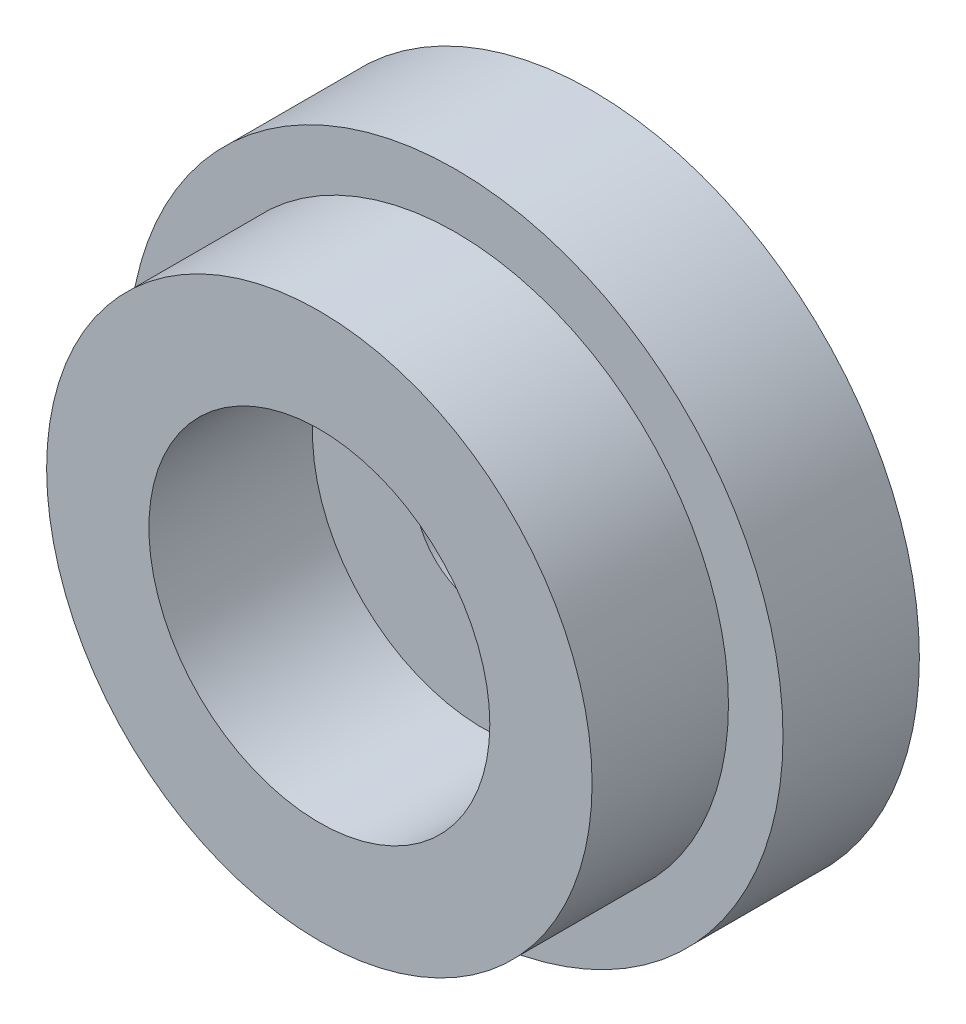
from build123d import *

# Parameters (mm, degrees)
SKETCH_2_R          = 20
EXTRUDE_1_DEPTH     = 10
SKETCH_3_R          = 5
CUT_EXTRUDE_1_DEPTH = 21
SKETCH_4_R          = 12.5
CUT_EXTRUDE_2_DEPTH = 12


with BuildPart() as part:
    # 草图1 → 旋转1 (revolve)
    with BuildSketch(Plane(origin=(0, 0, 0), x_dir=(0, 0, -1), z_dir=(1, 0, 0))):
        Polygon((0, 0), (0, 24), (10, 24), (10, 10.45), (8, 10.45), (8, 0), align=None)
    revolve(axis=Axis((0, 0, 0), (0, 0, -1)))

    # 草图2 → 凸台-拉伸1 (add)
    with BuildSketch(Plane.XY):
        Circle(SKETCH_2_R)
    extrude(amount=EXTRUDE_1_DEPTH)

    # 草图3 → 切除-拉伸1 (cut, through all)
    with BuildSketch(Plane.XY.offset(10)):
        Circle(SKETCH_3_R)
    extrude(amount=-CUT_EXTRUDE_1_DEPTH, mode=Mode.SUBTRACT)

    # 草图4 → 切除-拉伸2 (cut)
    with BuildSketch(Plane.XY.offset(10)):
        Circle(SKETCH_4_R)
    extrude(amount=-CUT_EXTRUDE_2_DEPTH, mode=Mode.SUBTRACT)


solid = part.part
